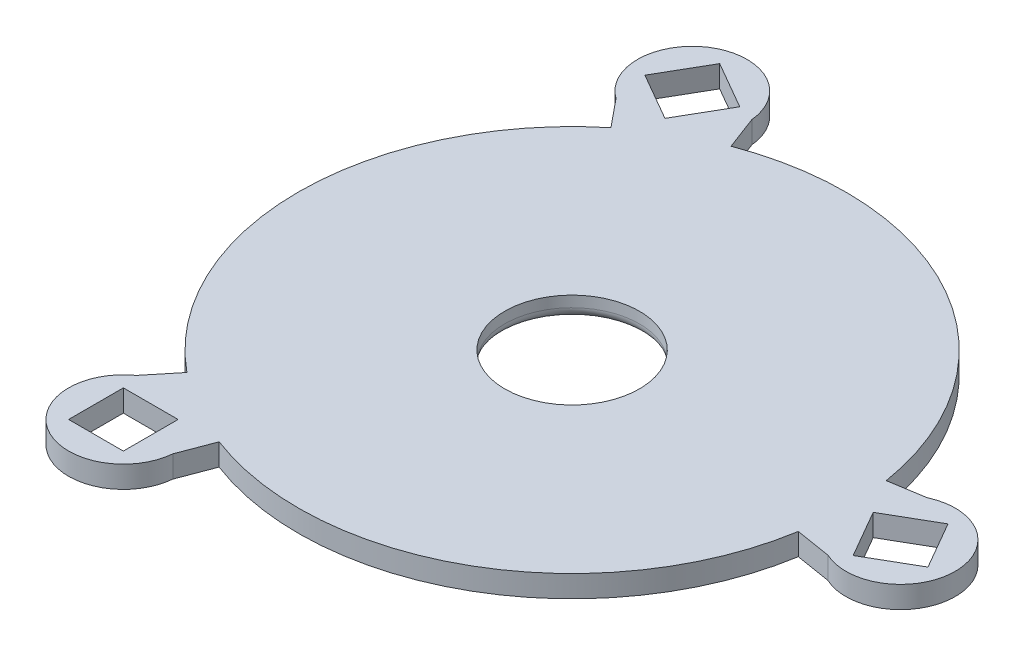
from build123d import *

# Parameters (mm, degrees)
SKETCH1_W           = 5
SKETCH1_H           = 5
BOSS_EXTRUDE1_DEPTH = 2
CUT_EXTRUDE1_REACH  = 48.785
SKETCH2_R           = 6.15
FILLET1_R           = 1


with BuildPart() as part:
    # Sketch1 → Boss-Extrude1 (new body)
    with BuildSketch(Plane(origin=(0, 0, 0), x_dir=(1, 0, 0), z_dir=(0, 1, 0))):
        with BuildLine():
            ThreePointArc((-8.860443092, -23.377180074), (12.5, -21.650635095), (24.675453359, -4.01522123))
            Line((24.675453359, -4.01522123), (27.907701299, -4.541176736))
            ThreePointArc((27.907701299, -4.541176736), (35, 0), (27.907701299, 4.541176736))
            Line((27.907701299, 4.541176736), (24.675453359, 4.01522123))
            ThreePointArc((24.675453359, 4.01522123), (12.5, 21.650635095), (-8.860443092, 23.377180074))
            Line((-8.860443092, 23.377180074), (-10.021076233, 26.439366654))
            ThreePointArc((-10.021076233, 26.439366654), (-17.5, 30.310889132), (-17.886625066, 21.898189918))
            Line((-17.886625066, 21.898189918), (-15.815010267, 19.361958844))
            ThreePointArc((-15.815010267, 19.361958844), (-25, 0), (-15.815010267, -19.361958844))
            Line((-15.815010267, -19.361958844), (-17.886625066, -21.898189918))
            ThreePointArc((-17.886625066, -21.898189918), (-17.5, -30.310889132), (-10.021076233, -26.439366654))
            Line((-10.021076233, -26.439366654), (-8.860443092, -23.377180074))
        make_face()
        with Locations((-15, -25.980762114)):
            Rectangle(SKETCH1_W, SKETCH1_H, mode=Mode.SUBTRACT)
        Polygon((26.584936491, 0.915063509), (30.915063509, 3.415063509), (33.415063509, -0.915063509), (29.084936491, -3.415063509), align=None, mode=Mode.SUBTRACT)
        Polygon((-11.584936491, 26.895825623), (-14.084936491, 22.565698604), (-18.415063509, 25.065698604), (-15.915063509, 29.395825623), align=None, mode=Mode.SUBTRACT)
    extrude(amount=BOSS_EXTRUDE1_DEPTH)

    # Sketch2 → Cut-Extrude1 (cut, up to next)
    with BuildSketch(Plane(origin=(0, 0, 0), x_dir=(-1, 0, 0), z_dir=(0, -1, 0)), mode=Mode.PRIVATE) as cut_extrude1_sk1:
        Circle(SKETCH2_R)
    cut_extrude1_tool1 = extrude(cut_extrude1_sk1.sketch, amount=-CUT_EXTRUDE1_REACH, mode=Mode.PRIVATE) & part.part
    add(cut_extrude1_tool1.solids().sort_by_distance((0, 0, 0))[0], mode=Mode.SUBTRACT)

    # Fillet1
    fillet1_edges = [part.edges().sort_by_distance(p)[0] for p in [
        (6.15, 0, 0),
    ]]
    fillet(fillet1_edges, radius=FILLET1_R)


solid = part.part
